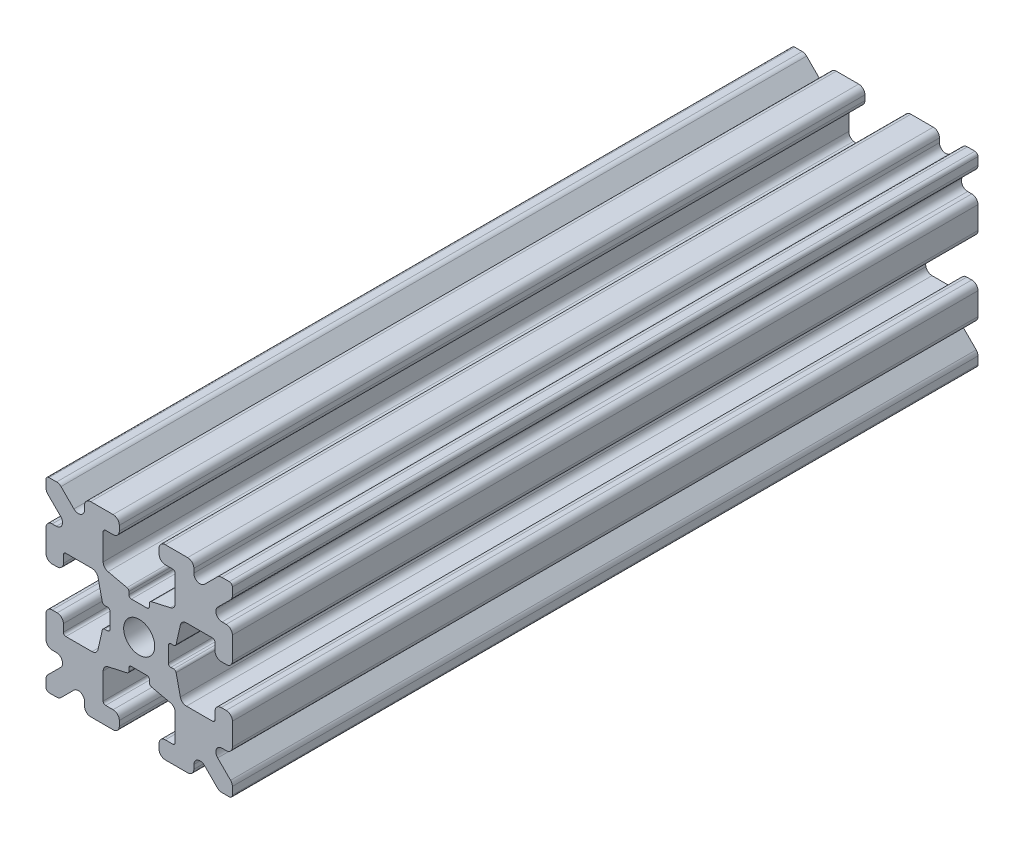
from build123d import *

# Parameters (mm, degrees)
SKETCH1_W           = 15
SKETCH1_H           = 15
SKETCH1_R           = 1.25
BOSS_EXTRUDE1_DEPTH = 30
FILLET1_R           = 0.25
CUT_EXTRUDE1_DEPTH  = 61
CUT_EXTRUDE3_DEPTH  = 61
FILLET3_R           = 0.5
FILLET4_R           = 0.5
FILLET5_R           = 3
FILLET6_R           = 0.2
CUT_EXTRUDE4_DEPTH  = 61
FILLET8_R           = 0.5
SKETCH6_W           = 5.1529354
SKETCH6_H           = 1.651
SKETCH6_W_2         = 1.651
SKETCH6_H_2         = 5.1529354
CUT_EXTRUDE5_DEPTH  = 61
FILLET10_R          = 0.2


with BuildPart() as part:
    # Sketch1 → Boss-Extrude1 (new body, symmetric)
    with BuildSketch(Plane.XY):
        Rectangle(SKETCH1_W, SKETCH1_H)
        Circle(SKETCH1_R, mode=Mode.SUBTRACT)
    extrude(amount=BOSS_EXTRUDE1_DEPTH, both=True)

    # Fillet1
    fillet1_edges = [part.edges().sort_by_distance(p)[0] for p in [
        (7.5, -7.5, 0),
        (-7.5, -7.5, 0),
        (-7.5, 7.5, 0),
        (7.5, 7.5, 0),
    ]]
    fillet(fillet1_edges, radius=FILLET1_R)

    # Sketch2 → Cut-Extrude1 (cut, through all)
    with BuildSketch(Plane.XY.offset(30)):
        Polygon((-7.5, 1.6), (-6.1, 1.6), (-6.1, 2.9), (-3.4, 2.9), (-3.4, -2.9), (-6.1, -2.9), (-6.1, -1.6), (-7.5, -1.6), align=None)
        Polygon((2.9, 6.1), (1.6, 6.1), (1.6, 7.5), (-1.6, 7.5), (-1.6, 6.1), (-2.9, 6.1), (-2.9, 3.4), (2.9, 3.4), align=None)
        Polygon((-1.6, -7.5), (-1.6, -6.1), (-2.9, -6.1), (-2.9, -3.4), (2.9, -3.4), (2.9, -6.1), (1.6, -6.1), (1.6, -7.5), align=None)
        Polygon((6.1, -2.9), (6.1, -1.6), (7.5, -1.6), (7.5, 1.6), (6.1, 1.6), (6.1, 2.9), (3.4, 2.9), (3.4, -2.9), align=None)
    extrude(amount=-CUT_EXTRUDE1_DEPTH, mode=Mode.SUBTRACT)

    # Sketch4 → Cut-Extrude3 (cut, through all)
    with BuildSketch(Plane.XY.offset(30)):
        Polygon((-3.4, 2.9), (-2.75, 0), (-3.4, -2.9), align=None)
        Polygon((-2.9, 3.4), (0, 2.75), (2.9, 3.4), align=None)
        Polygon((3.4, 2.9), (2.75, 0), (3.4, -2.9), align=None)
        Polygon((-2.9, -3.4), (0, -2.75), (2.9, -3.4), align=None)
    extrude(amount=-CUT_EXTRUDE3_DEPTH, mode=Mode.SUBTRACT)

    # Fillet3
    fillet3_edges = [part.edges().sort_by_distance(p)[0] for p in [
        (1.6, -7.5, 0),
        (-1.6, -7.5, 0),
        (-1.6, -6.1, 0),
        (1.6, -6.1, 0),
        (6.1, 1.6, 0),
        (7.5, 1.6, 0),
        (7.5, -1.6, 0),
        (6.1, -1.6, 0),
        (-7.5, -1.6, 0),
        (-7.5, 1.6, 0),
        (-6.1, 1.6, 0),
        (-6.1, -1.6, 0),
        (-1.6, 6.1, 0),
        (-1.6, 7.5, 0),
        (1.6, 7.5, 0),
        (1.6, 6.1, 0),
    ]]
    fillet(fillet3_edges, radius=FILLET3_R)

    # Fillet4
    fillet4_edges = [part.edges().sort_by_distance(p)[0] for p in [
        (-2.9, -3.4, 0),
        (2.9, -3.4, 0),
        (3.4, -2.9, 0),
        (3.4, 2.9, 0),
        (-3.4, 2.9, 0),
        (-3.4, -2.9, 0),
        (2.9, 3.4, 0),
        (-2.9, 3.4, 0),
    ]]
    fillet(fillet4_edges, radius=FILLET4_R)

    # Fillet5
    fillet5_edges = [part.edges().sort_by_distance(p)[0] for p in [
        (-2.75, 0, 0),
        (0, 2.75, 0),
        (2.75, 0, 0),
        (0, -2.75, 0),
    ]]
    fillet(fillet5_edges, radius=FILLET5_R)

    # Fillet6
    fillet6_edges = [part.edges().sort_by_distance(p)[0] for p in [
        (-2.9, -6.1, 0),
        (2.9, -6.1, 0),
        (6.1, -2.9, 0),
        (6.1, 2.9, 0),
        (-6.1, 2.9, 0),
        (-6.1, -2.9, 0),
        (2.9, 6.1, 0),
        (-2.9, 6.1, 0),
    ]]
    fillet(fillet6_edges, radius=FILLET6_R)

    # Sketch5 → Cut-Extrude4 (cut, through all)
    with BuildSketch(Plane.XY.offset(30)):
        Polygon((-7.5, 6.439339828), (-5.460660172, 4.4), (-7.5, 4.4), align=None)
        Polygon((-6.439339828, 7.5), (-4.4, 5.460660172), (-4.4, 7.5), align=None)
        Polygon((4.4, 7.5), (6.439339828, 7.5), (4.4, 5.460660172), align=None)
        Polygon((7.5, 6.439339828), (7.5, 4.4), (5.460660172, 4.4), align=None)
        Polygon((7.5, -6.439339828), (5.460660172, -4.4), (7.5, -4.4), align=None)
        Polygon((6.439339828, -7.5), (4.4, -5.460660172), (4.4, -7.5), align=None)
        Polygon((-4.4, -7.5), (-6.439339828, -7.5), (-4.4, -5.460660172), align=None)
        Polygon((-7.5, -6.439339828), (-7.5, -4.4), (-5.460660172, -4.4), align=None)
    extrude(amount=-CUT_EXTRUDE4_DEPTH, mode=Mode.SUBTRACT)

    # Fillet8
    fillet8_edges = [part.edges().sort_by_distance(p)[0] for p in [
        (-7.5, 4.4, 0),
        (-7.5, 6.439339828, 0),
        (-5.460660172, 4.4, 0),
        (7.5, -4.4, 0),
        (7.5, -6.439339828, 0),
        (5.460660172, -4.4, 0),
        (5.460660172, 4.4, 0),
        (7.5, 6.439339828, 0),
        (7.5, 4.4, 0),
        (-4.4, 7.5, 0),
        (-4.4, 5.460660172, 0),
        (-6.439339828, 7.5, 0),
        (-5.460660172, -4.4, 0),
        (-7.5, -6.439339828, 0),
        (-7.5, -4.4, 0),
        (4.4, 5.460660172, 0),
        (4.4, 7.5, 0),
        (6.439339828, 7.5, 0),
        (6.439339828, -7.5, 0),
        (4.4, -7.5, 0),
        (4.4, -5.460660172, 0),
        (-6.439339828, -7.5, 0),
        (-4.4, -5.460660172, 0),
        (-4.4, -7.5, 0),
    ]]
    fillet(fillet8_edges, radius=FILLET8_R)

    # Sketch6 → Cut-Extrude5 (cut, through all)
    with BuildSketch(Plane.XY.offset(30)):
        with Locations((4.9235323, 0)):
            Rectangle(SKETCH6_W, SKETCH6_H)
        with Locations((0, -4.9235323)):
            Rectangle(SKETCH6_W_2, SKETCH6_H_2)
        with Locations((-4.9235323, 0)):
            Rectangle(SKETCH6_W, SKETCH6_H)
        with Locations((0, 4.9235323)):
            Rectangle(SKETCH6_W_2, SKETCH6_H_2)
    extrude(amount=-CUT_EXTRUDE5_DEPTH, mode=Mode.SUBTRACT)

    # Fillet10
    fillet10_edges = [part.edges().sort_by_distance(p)[0] for p in [
        (0.8255, -2.935025862, 0),
        (-0.8255, -2.935025862, 0),
        (0.8255, -2.3470646, 0),
        (-0.8255, -2.3470646, 0),
        (2.935025862, 0.8255, 0),
        (2.935025862, -0.8255, 0),
        (2.3470646, 0.8255, 0),
        (2.3470646, -0.8255, 0),
        (-2.935025862, -0.8255, 0),
        (-2.935025862, 0.8255, 0),
        (-2.3470646, -0.8255, 0),
        (-2.3470646, 0.8255, 0),
        (-0.8255, 2.935025862, 0),
        (0.8255, 2.935025862, 0),
        (-0.8255, 2.3470646, 0),
        (0.8255, 2.3470646, 0),
    ]]
    fillet(fillet10_edges, radius=FILLET10_R)


solid = part.part
